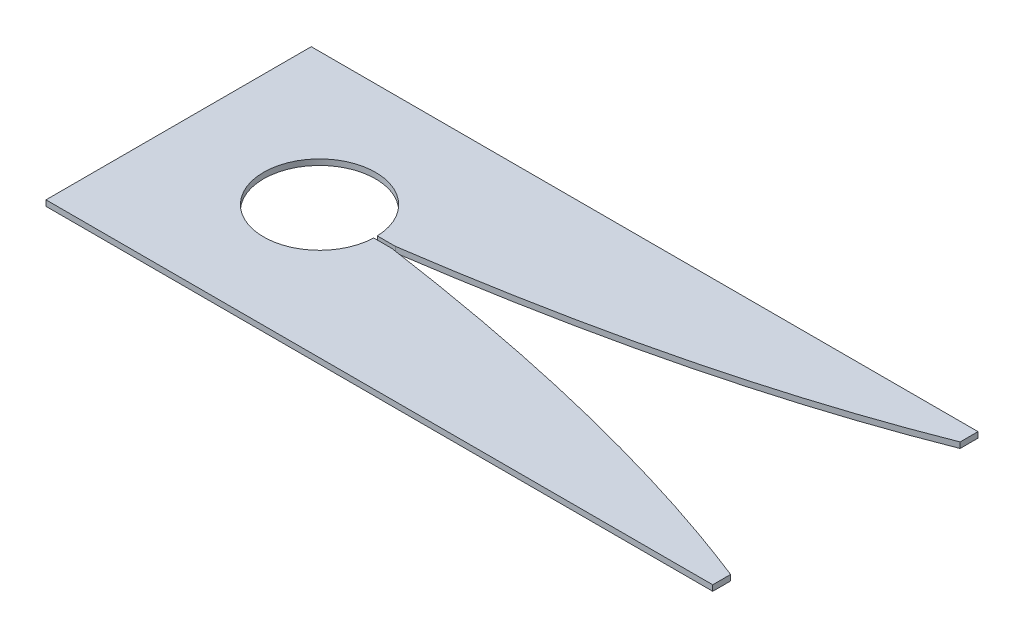
from build123d import *

# Parameters (mm, degrees)
SKETCH1_W           = 185.999882
SKETCH1_H           = 74.000106
BOSS_EXTRUDE3_DEPTH = 1.5875
CUT_EXTRUDE3_DEPTH  = 2.54


with BuildPart() as part:
    # Sketch1 → Boss-Extrude3 (new body)
    with BuildSketch(Plane(origin=(0, 0, 0), x_dir=(1, 0, 0), z_dir=(0, 1, 0))):
        Rectangle(SKETCH1_W, SKETCH1_H)
    extrude(amount=BOSS_EXTRUDE3_DEPTH)

    # Sketch4 → Cut-Extrude3 (cut)
    with BuildSketch(Plane(origin=(0, 1.5875, 0), x_dir=(1, 0, 0), z_dir=(0, 1, 0))):
        with BuildLine():
            Line((-33.019999998, 0.499998888), (-38.076346482, 0.499998888))
            ThreePointArc((-38.076346482, 0.499998888), (-69.310342417, -8.5e-08), (-38.076346479, -0.499998888))
            Line((-38.076346479, -0.499998888), (-33.019999997, -0.499998888))
            add(Edge.make_bspline(
                [(-33.019999997, -0.499998888), (-32.54632499, -0.569245934), (-31.586035731, -0.710618844), (-29.370983979, -1.038906843), (-27.495063328, -1.325179383), (-25.000131636, -1.708121039), (-22.872397946, -2.043660099), (-20.526372341, -2.417494507), (-18.312405788, -2.778512003), (-16.022726377, -3.157194229), (-13.776510299, -3.536227287), (-10.945442388, -4.021942901), (-6.433516708, -4.814957325), (-1.356746681, -5.744470681), (4.270229912, -6.82483512), (11.013466622, -8.182339851), (16.620878036, -9.365479808), (22.217465189, -10.603163227), (28.231300592, -11.997433679), (33.11855172, -13.176234287), (37.994608625, -14.399821142), (42.858903514, -15.669688211), (47.285116507, -16.866229097), (51.7005538, -18.102139295), (56.104457025, -19.378378553), (59.947265614, -20.531258809), (63.232966999, -21.545846418), (65.965538205, -22.409292492), (68.147965495, -23.110854225), (70.871921061, -24.001687113), (73.589095471, -24.910758606), (76.029944312, -25.746275579), (78.193394279, -26.501694312), (79.81619039, -27.074902775), (81.432049585, -27.651976873), (83.324431409, -28.337781593), (85.465097243, -29.126327671), (87.359843247, -29.836757063), (88.94155129, -30.437597441), (90.322203412, -30.968739967), (91.291423843, -31.343800626), (92.282484454, -31.731855507), (92.741323404, -31.912151608), (92.964000003, -31.999935633)],
                knots=[0.081631279, 0.081631279, 0.081631279, 0.081631279, 0.081631279, 0.096343802, 0.111056325, 0.125768848, 0.140481371, 0.155193894, 0.169906418, 0.184618941, 0.199331464, 0.214043988, 0.228756511, 0.258181558, 0.31703165, 0.346456696, 0.375881743, 0.434731835, 0.464156881, 0.493581928, 0.534357317, 0.563782355, 0.593207404, 0.622632455, 0.652057492, 0.681482549, 0.710907585, 0.725620111, 0.740332636, 0.755045164, 0.769757692, 0.799182725, 0.813895254, 0.821251518, 0.828607782, 0.843320301, 0.858032821, 0.872745338, 0.887457856, 0.894814124, 0.902170393, 0.909526661, 0.91688293, 0.91688293, 0.91688293, 0.91688293, 0.91688293], degree=4))
            Line((92.964000003, -31.999935633), (94.190773048, -31.999935633))
            Line((94.190773048, -31.999935633), (94.190773048, 31.999935633))
            Line((94.190773048, 31.999935633), (92.964000001, 31.999935633))
            add(Edge.make_bspline(
                [(-33.019999998, 0.499998888), (-32.546324991, 0.569245934), (-31.586035733, 0.710618844), (-29.37098398, 1.038906842), (-27.495063329, 1.325179382), (-25.000131637, 1.708121039), (-22.872397948, 2.043660099), (-20.526372343, 2.417494507), (-18.312405789, 2.778512003), (-16.022726379, 3.157194229), (-13.7765103, 3.536227286), (-10.94544239, 4.021942901), (-6.433516709, 4.814957324), (-1.356746682, 5.744470681), (4.27022991, 6.82483512), (11.01346662, 8.182339851), (16.620878035, 9.365479808), (22.217465188, 10.603163227), (28.231300591, 11.997433679), (33.118551718, 13.176234287), (37.994608623, 14.399821142), (42.858903512, 15.669688211), (47.285116506, 16.866229097), (51.700553798, 18.102139295), (56.104457023, 19.378378554), (59.947265613, 20.531258809), (63.232966997, 21.545846418), (65.965538204, 22.409292493), (68.147965493, 23.110854225), (70.87192106, 24.001687113), (73.58909547, 24.910758606), (76.02994431, 25.746275579), (78.193394278, 26.501694312), (79.816190388, 27.074902775), (81.432049584, 27.651976873), (83.324431408, 28.337781594), (85.465097241, 29.126327672), (87.359843245, 29.836757063), (88.941551288, 30.437597442), (90.322203411, 30.968739967), (91.291423842, 31.343800626), (92.282484452, 31.731855507), (92.741323403, 31.912151608), (92.964000001, 31.999935633)],
                knots=[0.081631279, 0.081631279, 0.081631279, 0.081631279, 0.081631279, 0.096343802, 0.111056325, 0.125768848, 0.140481371, 0.155193894, 0.169906418, 0.184618941, 0.199331464, 0.214043988, 0.228756511, 0.258181558, 0.31703165, 0.346456696, 0.375881743, 0.434731835, 0.464156881, 0.493581928, 0.534357317, 0.563782355, 0.593207404, 0.622632455, 0.652057492, 0.681482549, 0.710907585, 0.725620111, 0.740332636, 0.755045164, 0.769757692, 0.799182725, 0.813895254, 0.821251518, 0.828607782, 0.843320301, 0.858032821, 0.872745338, 0.887457856, 0.894814124, 0.902170393, 0.909526661, 0.91688293, 0.91688293, 0.91688293, 0.91688293, 0.91688293], degree=4))
        make_face()
    extrude(amount=-CUT_EXTRUDE3_DEPTH, mode=Mode.SUBTRACT)


solid = part.part
